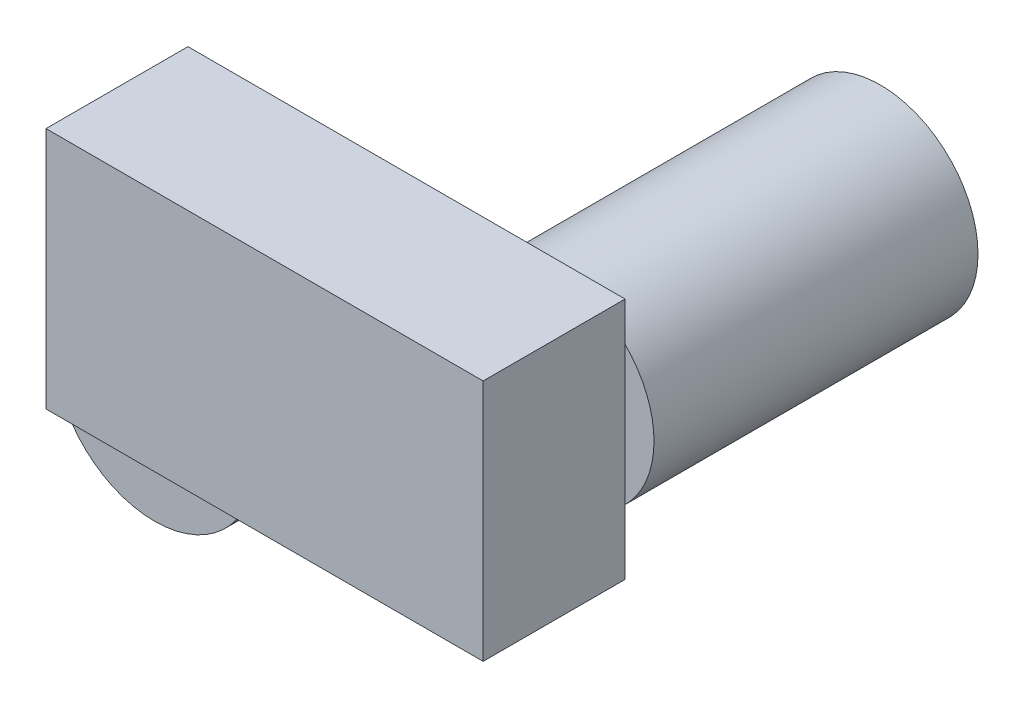
from build123d import *

# Parameters (mm, degrees)
SKETCH1_R          = 19
EXTRUDE13_DEPTH    = 63
EXTRUDE15_DEPTH    = 17
SKETCH2_R          = 19.5
EXTRUDE18_DEPTH    = 24
SKETCH2_6_R        = 19.5
CUT_EXTRUDE1_DEPTH = 14.38
SKETCH7_W          = 85
SKETCH7_H          = 47.220330203
EXTRUDE21_DEPTH    = 27.6


with BuildPart() as part:
    # Sketch1 → Extrude13 (new body)
    with BuildSketch(Plane.XY):
        with Locations((9.080174701, 18.537445764)):
            Circle(SKETCH1_R)
        with BuildLine():
            ThreePointArc((-0.037230939, 16.976864339), (-0.16055511, 18.123425772), (-0.140259902, 19.276421901))
            ThreePointArc((-0.140259902, 19.276421901), (-0.057438126, 18.128045807), (-0.037230939, 16.976864339))
        make_face(mode=Mode.SUBTRACT)
    extrude(amount=-EXTRUDE13_DEPTH)

    # Sketch1_17 → Extrude15 (add)
    with BuildSketch(Plane.XY):
        with BuildLine():
            ThreePointArc((-0.140259902, 19.276421901), (-0.057438126, 18.128045807), (-0.037230939, 16.976864339))
            ThreePointArc((-0.037230939, 16.976864339), (18.320904513, 18.951465757), (-0.140259902, 19.276421901))
        make_face()
    extrude(amount=EXTRUDE15_DEPTH)



with BuildPart() as body_2:
    # Sketch2 → Extrude18 (new body)
    with BuildSketch(Plane.XY):
        with Locations((-45.03001877, 0)):
            Circle(SKETCH2_R)
    extrude(amount=EXTRUDE18_DEPTH)

    # Sketch2_6 → Cut-Extrude1 (cut)
    with BuildSketch(Plane.XY):
        with Locations((-45.03001877, 0)):
            Circle(SKETCH2_6_R)
    extrude(amount=CUT_EXTRUDE1_DEPTH, mode=Mode.SUBTRACT)


with BuildPart() as part_1:
    add(part.part)

    add(body_2.part)  # Extrude21 merges body 2
    # Sketch7 → Extrude21 (add)
    with BuildSketch(Plane.XY):
        with Locations((-20.041402411, 16.059391911)):
            Rectangle(SKETCH7_W, SKETCH7_H)
    extrude(amount=EXTRUDE21_DEPTH)


solid = part_1.part
